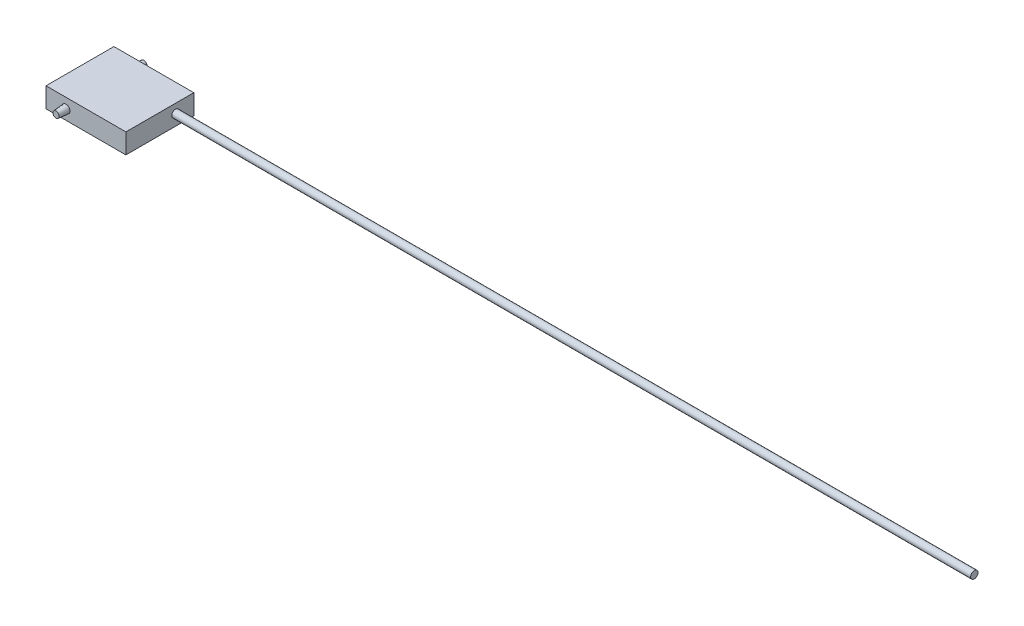
from build123d import *

# Parameters (mm, degrees)
SKETCH1_W           = 25.4
SKETCH1_H           = 21.59
BOSS_EXTRUDE1_DEPTH = 6.35
SKETCH2_R           = 1.27
BOSS_EXTRUDE2_DEPTH = 3.175
BOSS_EXTRUDE2_TAPER = 5
SKETCH3_R           = 1.169045739
BOSS_EXTRUDE3_DEPTH = 254


with BuildPart() as part:
    # Sketch1 → Boss-Extrude1 (new body)
    with BuildSketch(Plane(origin=(0, 0, 0), x_dir=(1, 0, 0), z_dir=(0, 1, 0))):
        Rectangle(SKETCH1_W, SKETCH1_H)
    extrude(amount=BOSS_EXTRUDE1_DEPTH)

    # Sketch2 → Boss-Extrude2 (add)
    with BuildSketch(Plane.XY.offset(10.795)):
        with Locations((-6.35, 3.175)):
            Circle(SKETCH2_R)
    boss_extrude2 = extrude(amount=BOSS_EXTRUDE2_DEPTH, taper=BOSS_EXTRUDE2_TAPER)

    # Mirror1: Boss-Extrude2 across plane
    add(boss_extrude2.mirror(Plane.XY))

    # Sketch3 → Boss-Extrude3 (add)
    with BuildSketch(Plane(origin=(12.7, 0, 0), x_dir=(0, 0, -1), z_dir=(1, 0, 0))):
        with Locations((4.956387533, 3.55)):
            Circle(SKETCH3_R)
    extrude(amount=BOSS_EXTRUDE3_DEPTH)


solid = part.part
